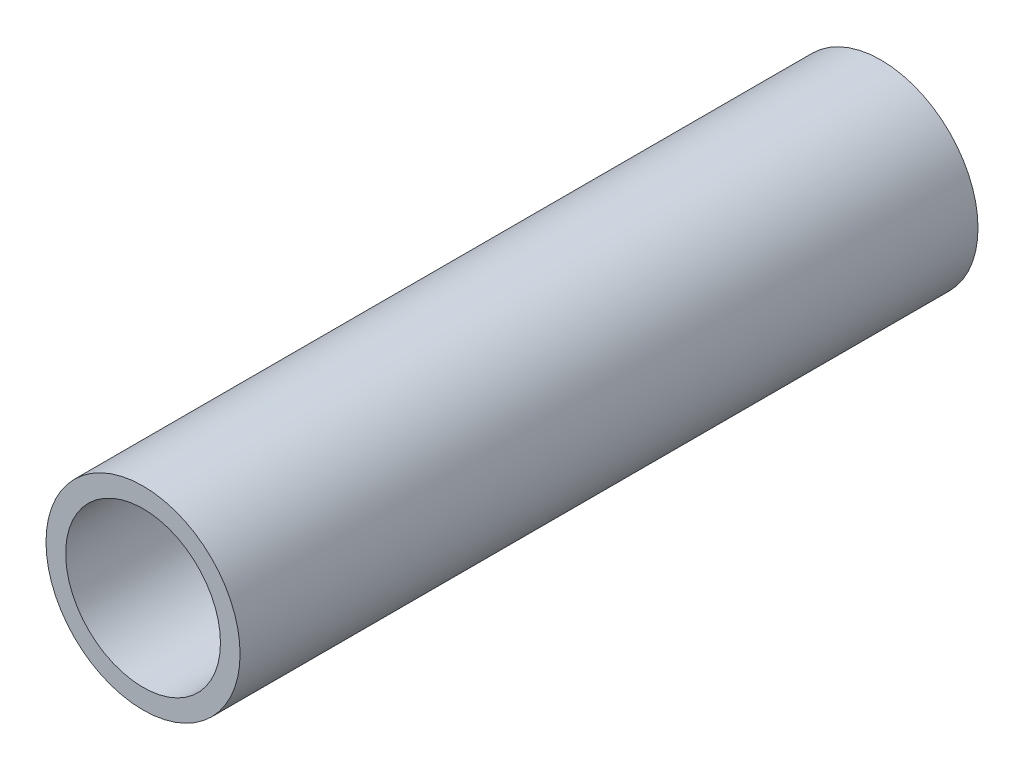
from build123d import *

# Parameters (mm, degrees)
SKETCH1_R           = 16.7005
SKETCH1_R_2         = 13.3223
EXTRUDE_THIN1_DEPTH = 63.5


with BuildPart() as part:
    # Sketch1 → Extrude-Thin1 (new body, symmetric)
    with BuildSketch(Plane.XY):
        Circle(SKETCH1_R)
        Circle(SKETCH1_R_2, mode=Mode.SUBTRACT)
    extrude(amount=EXTRUDE_THIN1_DEPTH, both=True)


solid = part.part
